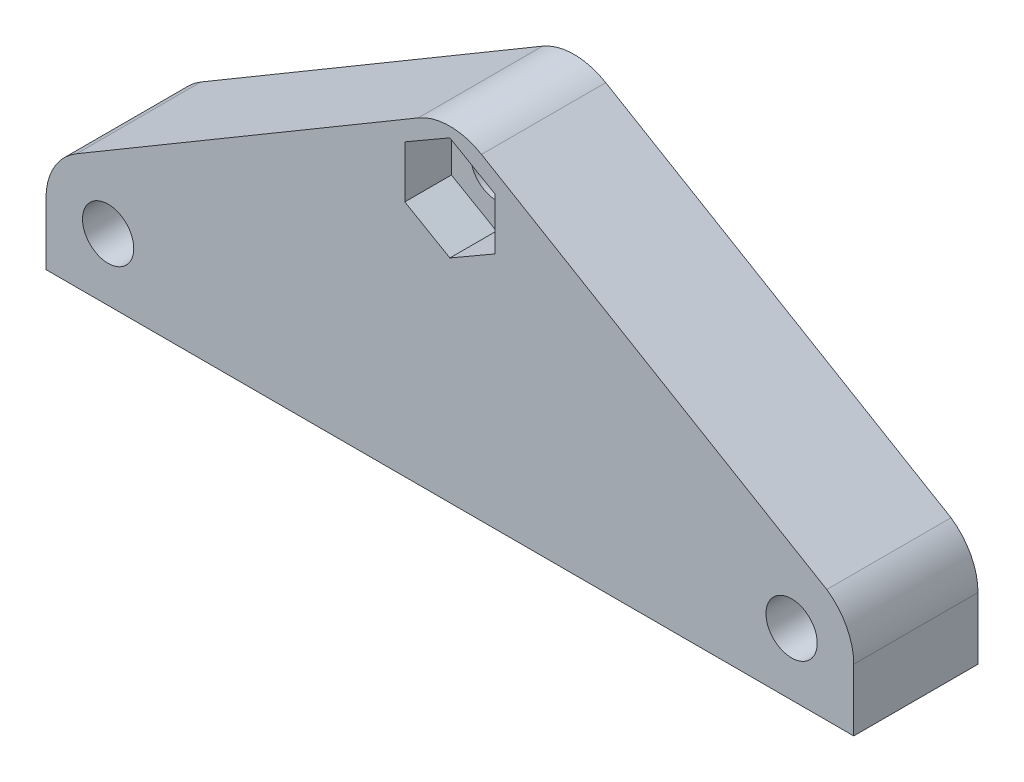
from build123d import *

# Parameters (mm, degrees)
SKETCH1_R           = 1.65
BOSS_EXTRUDE1_DEPTH = 8
CUT_EXTRUDE1_DEPTH  = 3


with BuildPart() as part:
    # Sketch1 → Boss-Extrude1 (new body)
    with BuildSketch(Plane.XY):
        with BuildLine():
            Line((0, 0), (52, 0))
            Line((52, 0), (52, 4))
            ThreePointArc((52, 4), (51.538809184, 5.864625849), (50.261585222, 7.29927754))
            Line((50.261585222, 7.29927754), (28.036121371, 20.442994302))
            ThreePointArc((28.036121371, 20.442994302), (26.00069939, 20.999999939), (23.965082751, 20.443706113))
            Line((23.965082751, 20.443706113), (1.965082751, 7.443706113))
            ThreePointArc((1.965082751, 7.443706113), (0.525833266, 5.982464502), (0, 4))
            Line((0, 4), (0, 0))
        make_face()
        with Locations((26, 17)):
            Circle(SKETCH1_R, mode=Mode.SUBTRACT)
        with Locations((4, 4)):
            Circle(SKETCH1_R, mode=Mode.SUBTRACT)
        with Locations((48, 4)):
            Circle(SKETCH1_R, mode=Mode.SUBTRACT)
    extrude(amount=BOSS_EXTRUDE1_DEPTH)

    # Sketch2 → Cut-Extrude1 (cut)
    with BuildSketch(Plane.XY.offset(8)):
        Polygon((26, 13.651368439), (28.9, 15.325684219), (28.9, 18.674315781), (26, 20.348631561), (23.1, 18.674315781), (23.1, 15.325684219), align=None)
    extrude(amount=-CUT_EXTRUDE1_DEPTH, mode=Mode.SUBTRACT)


solid = part.part
